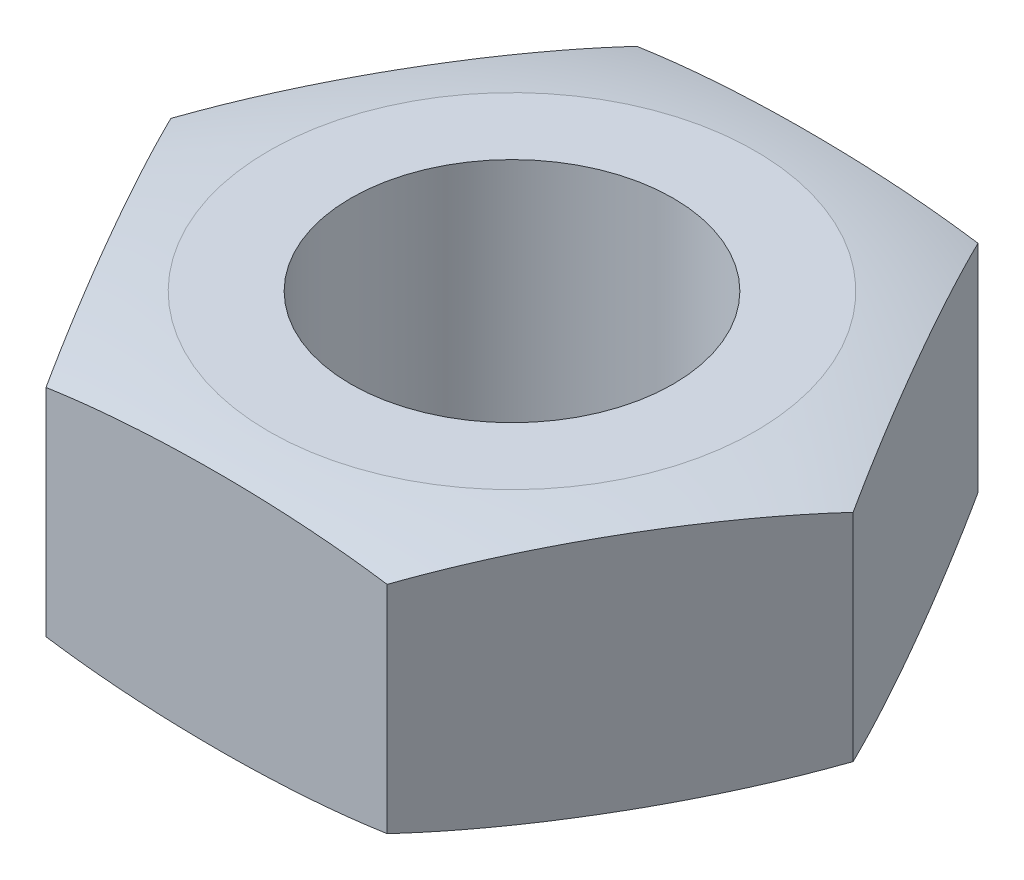
from build123d import *

# Parameters (mm, degrees)
ESBO_O1_R                = 1.5
RESSALTO_EXTRUS_O1_DEPTH = 2.4


with BuildPart() as part:
    # Esboço1 → Ressalto-extrusão1 (new body)
    with BuildSketch(Plane(origin=(0, 0, 0), x_dir=(1, 0, 0), z_dir=(0, 1, 0))):
        Polygon((3.175426481, 0), (1.58771324, 2.75), (-1.58771324, 2.75), (-3.175426481, 0), (-1.58771324, -2.75), (1.58771324, -2.75), align=None)
        Circle(ESBO_O1_R, mode=Mode.SUBTRACT)
    extrude(amount=RESSALTO_EXTRUS_O1_DEPTH)

    # Esboço3 → Corte-Revolução1 (revolve, cut)
    with BuildSketch(Plane.XY):
        with BuildLine():
            Line((1.5, 2.45), (1.5, 3.039454742))
            Line((1.5, 3.039454742), (3.5, 3.039454742))
            Line((3.5, 3.039454742), (3.5, 2.097346039))
            ThreePointArc((3.5, 2.097346039), (2.515426612, 2.361161683), (1.5, 2.45))
        make_face()
        with BuildLine():
            ThreePointArc((1.5, -0.05), (2.515426612, 0.038838317), (3.5, 0.302653961))
            Line((3.5, 0.302653961), (3.5, -0.837086604))
            Line((3.5, -0.837086604), (1.5, -0.837086604))
            Line((1.5, -0.837086604), (1.5, -0.05))
        make_face()
    revolve(axis=Axis((0, 0, 0), (0, 1, 0)), mode=Mode.SUBTRACT)


solid = part.part
